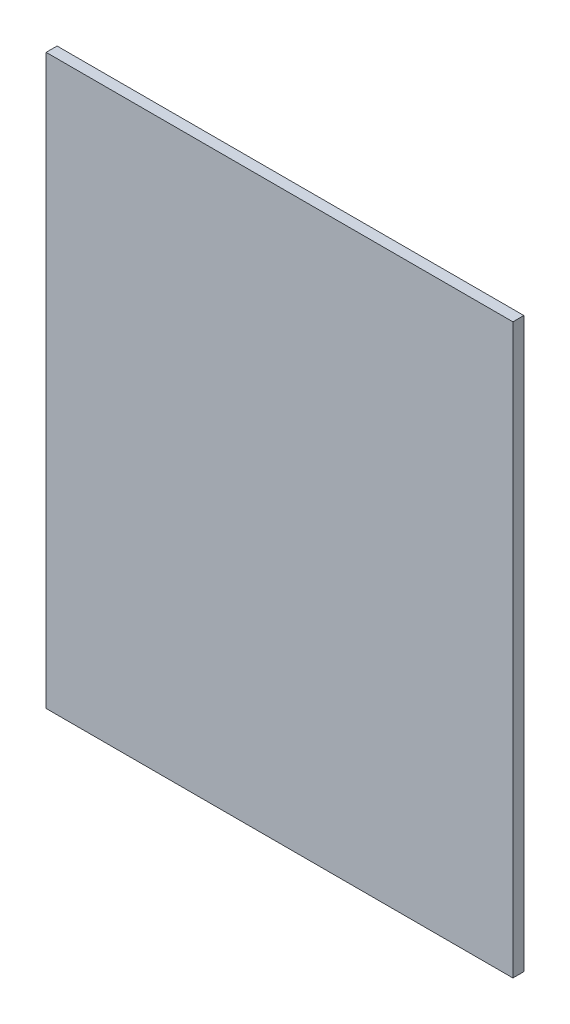
from build123d import *

# Parameters (mm, degrees)
SKETCH2_W           = 115
SKETCH2_H           = 140
BOSS_EXTRUDE1_DEPTH = 2.7


with BuildPart() as part:
    # Sketch2 → Boss-Extrude1 (new body)
    with BuildSketch(Plane.XY):
        with Locations((94.384088259, -362.926224712)):
            Rectangle(SKETCH2_W, SKETCH2_H)
    extrude(amount=BOSS_EXTRUDE1_DEPTH)


solid = part.part
